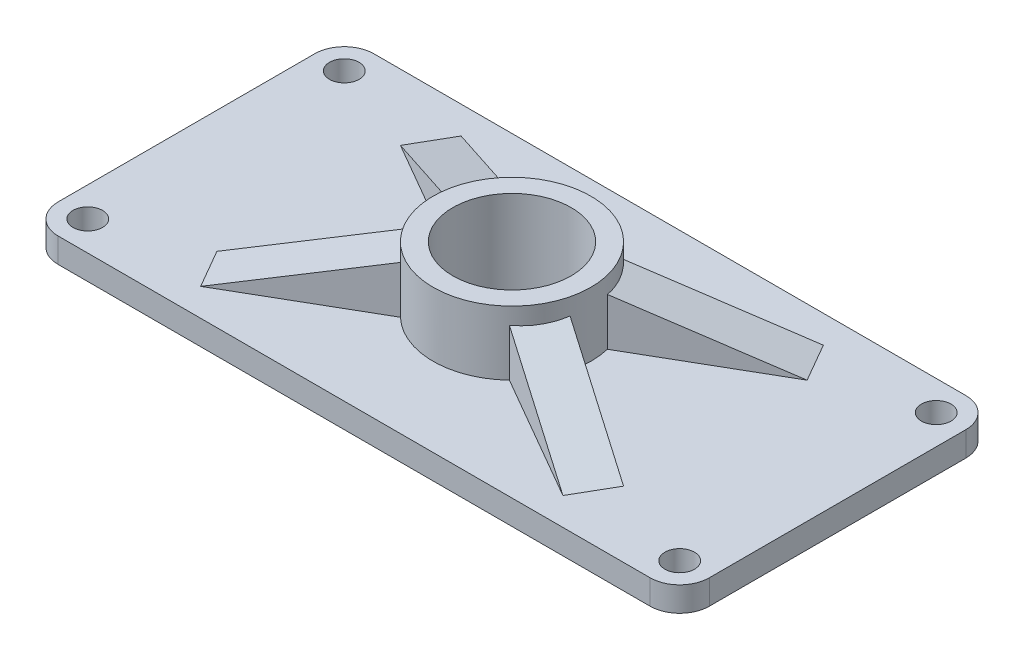
from build123d import *

# Parameters (mm, degrees)
SKETCH1_R               = 3
SKETCH1_R_2             = 12
BOSS_EXTRUDE1_DEPTH     = 5
SKETCH2_R               = 16
SKETCH2_R_2             = 12
BOSS_EXTRUDE2_DEPTH     = 13
RIB1_REACH              = 77.525
SKETCH5_WALL_W          = 183.54206521
SKETCH5_WALL_H          = 9
CIRPATTERN1_COUNT       = 2
MIRROR1_COPY_1_REACH    = 77.525
MIRROR1_COPY_1_SKETCH_W = 183.54206521
MIRROR1_COPY_1_SKETCH_H = 9


with BuildPart() as part:
    # Sketch1 → Boss-Extrude1 (new body)
    with BuildSketch(Plane(origin=(0, 0, 0), x_dir=(1, 0, 0), z_dir=(0, 1, 0))):
        with BuildLine():
            Line((-60, -32), (60, -32))
            ThreePointArc((60, -32), (64.242640687, -30.242640687), (66, -26))
            Line((66, -26), (66, 26))
            ThreePointArc((66, 26), (64.242640687, 30.242640687), (60, 32))
            Line((60, 32), (-60, 32))
            ThreePointArc((-60, 32), (-64.242640687, 30.242640687), (-66, 26))
            Line((-66, 26), (-66, -26))
            ThreePointArc((-66, -26), (-64.242640687, -30.242640687), (-60, -32))
        make_face()
        with Locations(Location((-60, 26, 0), (0, 0, 270))):
            Circle(SKETCH1_R, mode=Mode.SUBTRACT)
        with Locations(Location((60, 26, 0), (0, 0, 270))):
            Circle(SKETCH1_R, mode=Mode.SUBTRACT)
        with Locations(Location((60, -26, 0), (0, 0, 270))):
            Circle(SKETCH1_R, mode=Mode.SUBTRACT)
        with Locations(Location((-60, -26, 0), (0, 0, 270))):
            Circle(SKETCH1_R, mode=Mode.SUBTRACT)
        with Locations(Location((0, 0, 0), (0, 0, 270))):
            Circle(SKETCH1_R_2, mode=Mode.SUBTRACT)
    extrude(amount=BOSS_EXTRUDE1_DEPTH)

    # Sketch2 → Boss-Extrude2 (add)
    with BuildSketch(Plane(origin=(0, 5, 0), x_dir=(1, 0, 0), z_dir=(0, 1, 0))):
        with Locations(Location((0, 0, 0), (0, 0, 90))):
            Circle(SKETCH2_R)
        with Locations(Location((0, 0, 0), (0, 0, 270))):
            Circle(SKETCH2_R_2, mode=Mode.SUBTRACT)
    extrude(amount=BOSS_EXTRUDE2_DEPTH)

    # Sketch5 wall → Rib1 (add, up to next)
    with BuildSketch(Plane(origin=(26.413774815, 9.711335595, -15.25), x_dir=(-0.823639103536, 0.309016994388, 0.475528258156), z_dir=(0.267616567342, 0.951056516291, -0.154508497194)), mode=Mode.PRIVATE) as rib1_sk1:
        Rectangle(SKETCH5_WALL_W, SKETCH5_WALL_H)
    rib1_tool1 = extrude(rib1_sk1.sketch, amount=-RIB1_REACH, mode=Mode.PRIVATE) - part.part
    rib1 = rib1_tool1.solids().sort_by_distance((26.413774815, 9.711335595, -15.25))[0]
    add(rib1)

    # CirPattern1: Rib1 ×2 about axis
    cirpattern1_axis = Axis((0, 0, 0), (0, -1, 0))
    for i in range(1, CIRPATTERN1_COUNT):
        add(rib1.rotate(cirpattern1_axis, i * 360 / CIRPATTERN1_COUNT))

    # Mirror1: Rib1 across plane
    add(rib1.mirror(Plane(origin=(0, 0, 0), x_dir=(0, 0, 1), z_dir=(1, 0, 0))))

    # Mirror1 copy 1 sketch → Mirror1 copy 1 (add, up to next)
    with BuildSketch(Plane(origin=(26.413774815, 9.711335595, 15.25), x_dir=(-0.8236391035359999, 0.309016994388, -0.47552825815600014), z_dir=(0.267616567342, 0.951056516291, 0.15450849719400003)), mode=Mode.PRIVATE) as mirror1_copy_1_sk1:
        Rectangle(MIRROR1_COPY_1_SKETCH_W, MIRROR1_COPY_1_SKETCH_H)
    mirror1_copy_1_tool1 = extrude(mirror1_copy_1_sk1.sketch, amount=-MIRROR1_COPY_1_REACH, mode=Mode.PRIVATE) - part.part
    add(mirror1_copy_1_tool1.solids().sort_by_distance((26.413774815, 9.711335595, 15.25))[0])


solid = part.part
